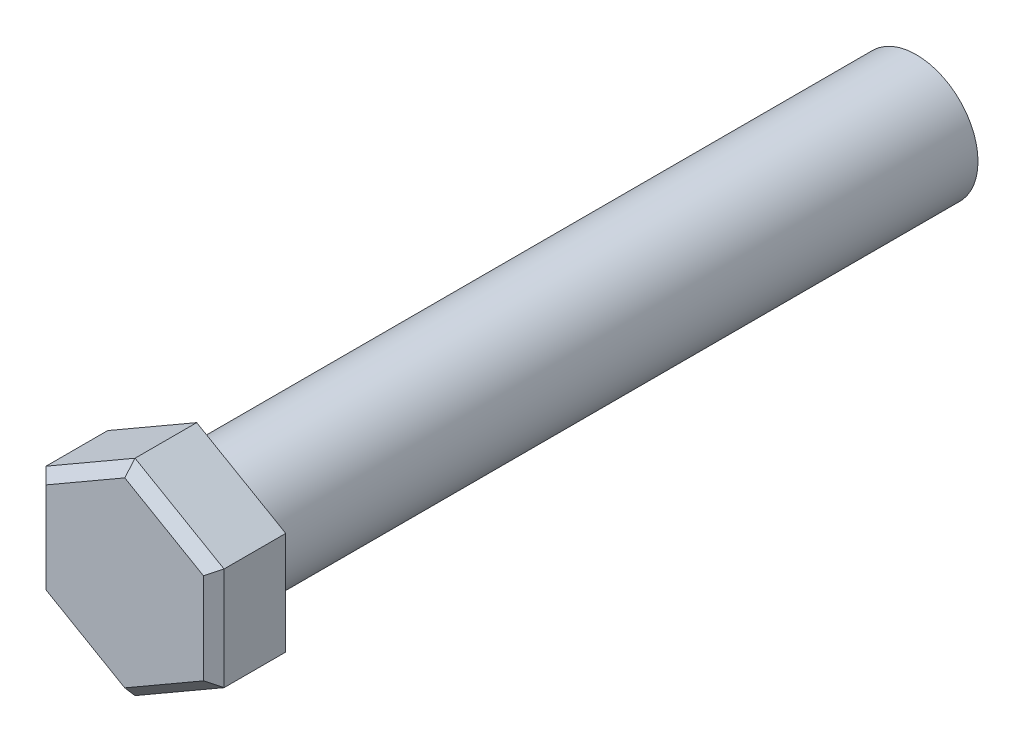
from build123d import *

# Parameters (mm, degrees)
CROQUIS1_R              = 6
SALIENTE_EXTRUIR3_DEPTH = 70
SALIENTE_EXTRUIR4_DEPTH = 7
CHAFL_N1_SIZE           = 1
REDONDEO1_R             = 1


with BuildPart() as part:
    # Croquis1 → Saliente-Extruir3 (new body)
    with BuildSketch(Plane.XY):
        Circle(CROQUIS1_R)
    extrude(amount=SALIENTE_EXTRUIR3_DEPTH)

    # Croquis3 → Saliente-Extruir4 (add)
    with BuildSketch(Plane.XY.offset(70)):
        Polygon((0, 10), (-8.660254038, 5), (-8.660254038, -5), (0, -10), (8.660254038, -5), (8.660254038, 5), align=None)
    extrude(amount=SALIENTE_EXTRUIR4_DEPTH)

    # Chaflán1
    chafl_n1_edges = [part.edges().sort_by_distance(p)[0] for p in [
        (8.660254038, 0, 77),
        (4.330127019, 7.5, 77),
        (-4.330127019, 7.5, 77),
        (-8.660254038, 0, 77),
        (-4.330127019, -7.5, 77),
        (4.330127019, -7.5, 77),
    ]]
    chamfer(chafl_n1_edges, length=CHAFL_N1_SIZE)

    # Redondeo1
    redondeo1_edges = [part.edges().sort_by_distance(p)[0] for p in [
        (-6, 0, 70),
    ]]
    fillet(redondeo1_edges, radius=REDONDEO1_R)


solid = part.part
